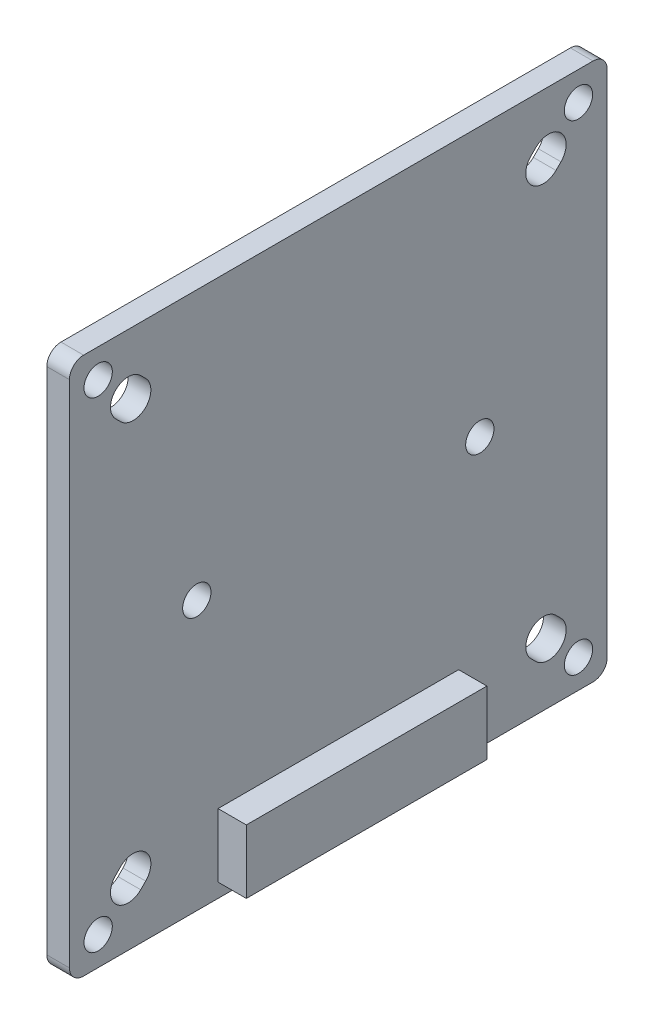
from build123d import *

# Parameters (mm, degrees)
ESQUISSE1_W                  = 38
ESQUISSE1_H                  = 38
BOSS_EXTRU_1_DEPTH           = 1.6
CONG_1_R                     = 1
ESQUISSE2_R                  = 1
ENL_V_MAT_EXTRU_1_DEPTH      = 27.917652201
ESQUISSE3_R                  = 1
ENL_V_MAT_EXTRU_2_DEPTH      = 27.917652201
R_P_TITION_CIRCULAIRE1_COUNT = 4
ESQUISSE4_W                  = 17
ESQUISSE4_H                  = 4.5
BOSS_EXTRU_2_DEPTH           = 2


with BuildPart() as part:
    # Esquisse1 → Boss.-Extru.1 (new body)
    with BuildSketch(Plane(origin=(0, 0, 0), x_dir=(0, 0, -1), z_dir=(1, 0, 0))):
        Rectangle(ESQUISSE1_W, ESQUISSE1_H)
    extrude(amount=BOSS_EXTRU_1_DEPTH)

    # Congé1
    cong_1_edges = [part.edges().sort_by_distance(p)[0] for p in [
        (0.8, -19, 19),
        (0.8, -19, -19),
        (0.8, 19, -19),
        (0.8, 19, 19),
    ]]
    fillet(cong_1_edges, radius=CONG_1_R)

    # Esquisse2 → Enlèv. mat.-Extru.1 (cut, through all)
    with BuildSketch(Plane(origin=(1.6, 0, 0), x_dir=(0, 0, -1), z_dir=(1, 0, 0))):
        with Locations((-10, 0)):
            Circle(ESQUISSE2_R)
        with Locations((10, 0)):
            Circle(ESQUISSE2_R)
    extrude(amount=-ENL_V_MAT_EXTRU_1_DEPTH, mode=Mode.SUBTRACT)

    # Esquisse3 → Enlèv. mat.-Extru.2 (cut, through all)
    with BuildSketch(Plane(origin=(1.6, 0, 0), x_dir=(0, 0, -1), z_dir=(1, 0, 0))):
        with Locations((16.970562748, 16.970562748)):
            Circle(ESQUISSE3_R)
        with BuildLine():
            Line((13.611805538, 15.379572491), (13.965358928, 15.733125881))
            ThreePointArc((13.965358928, 15.733125881), (15.733125881, 15.733125881), (15.733125881, 13.965358928))
            Line((15.733125881, 13.965358928), (15.379572491, 13.611805538))
            ThreePointArc((15.379572491, 13.611805538), (13.611805538, 13.611805538), (13.611805538, 15.379572491))
        make_face()
    enl_v_mat_extru_2 = extrude(amount=-ENL_V_MAT_EXTRU_2_DEPTH, mode=Mode.SUBTRACT)

    # Répétition circulaire1: Enlèv. mat.-Extru.2 ×4 about axis
    r_p_tition_circulaire1_axis = Axis((9.401737049, 0, 0), (-1, 0, 0))
    for i in range(1, R_P_TITION_CIRCULAIRE1_COUNT):
        add(enl_v_mat_extru_2.rotate(r_p_tition_circulaire1_axis, i * 360 / R_P_TITION_CIRCULAIRE1_COUNT), mode=Mode.SUBTRACT)

    # Esquisse4 → Boss.-Extru.2 (add)
    with BuildSketch(Plane(origin=(1.6, 0, 0), x_dir=(0, 0, -1), z_dir=(1, 0, 0))):
        with Locations((0, -15.75)):
            Rectangle(ESQUISSE4_W, ESQUISSE4_H)
    extrude(amount=BOSS_EXTRU_2_DEPTH)


solid = part.part
